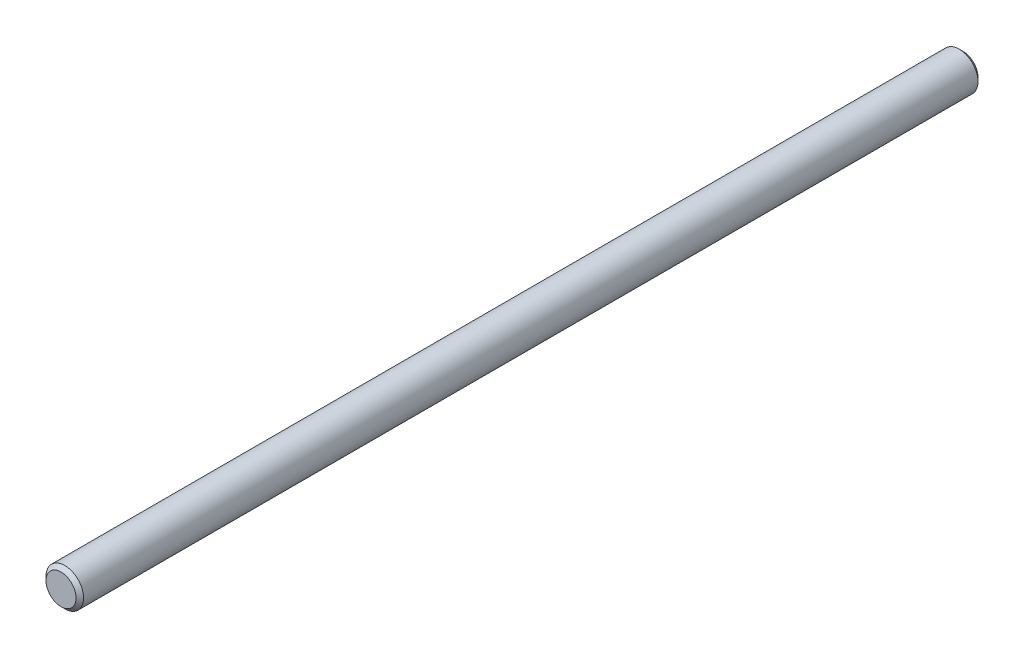
from build123d import *

# Parameters (mm, degrees)
SKETCH1_R      = 3.175
EXTRUDE1_DEPTH = 76.2
CHAMFER1_SIZE  = 0.635


with BuildPart() as part:
    # Sketch1 → Extrude1 (new body, symmetric)
    with BuildSketch(Plane.XY):
        Circle(SKETCH1_R)
    extrude(amount=EXTRUDE1_DEPTH, both=True)

    # Chamfer1
    chamfer1_edges = [part.edges().sort_by_distance(p)[0] for p in [
        (-3.175, 0, -76.2),
        (-3.175, 0, 76.2),
    ]]
    chamfer(chamfer1_edges, length=CHAMFER1_SIZE)


solid = part.part
